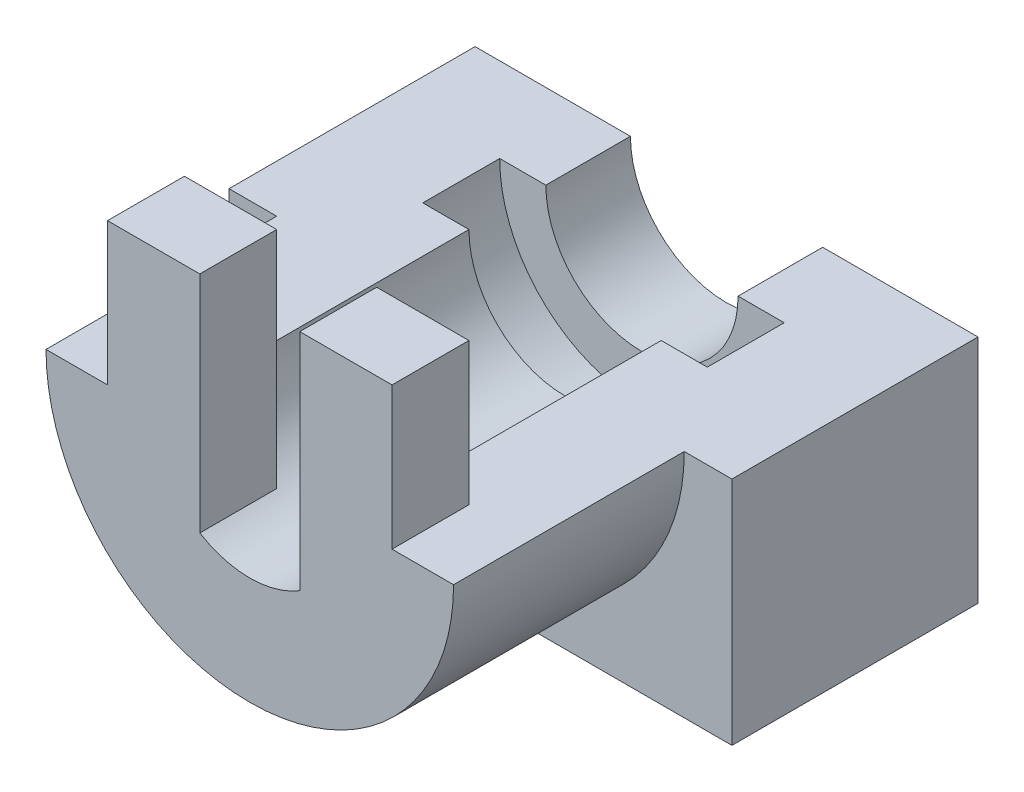
from build123d import *

# Parameters (mm, degrees)
EXTRUDE_1_DEPTH = 5
EXTRUDE_3_DEPTH = 10
EXTRUDE_4_DEPTH = 10.5
EXTRUDE_6_DEPTH = 15
EXTRUDE_7_DEPTH = 5.5
EXTRUDE_8_DEPTH = 5.5


with BuildPart() as part:
    # 草图1 → 凸台-拉伸1 (new body)
    with BuildSketch(Plane.XY):
        with BuildLine():
            Line((-3.25, 9.25), (-9.25, 9.25))
            Line((-9.25, 9.25), (-9.25, -1.7e-08))
            ThreePointArc((-9.25, -1.7e-08), (9e-09, -9.25), (9.25, 0))
            Line((9.25, 0), (9.25, 9.25))
            Line((9.25, 9.25), (3.25, 9.25))
            Line((3.25, 9.25), (3.25, -5.338539126))
            ThreePointArc((3.25, -5.338539126), (0, -6.25), (-3.25, -5.338539126))
            Line((-3.25, -5.338539126), (-3.25, 9.25))
        make_face()
    extrude(amount=EXTRUDE_1_DEPTH)

    # 草图1<4> → 凸台-拉伸3 (add)
    with BuildSketch(Plane.XY):
        with BuildLine():
            Line((-6.25, 0), (-9.25, 0))
            ThreePointArc((-9.25, -1.7e-08), (9e-09, -9.25), (9.25, 0))
            Line((9.25, 0), (6.25, 0))
            ThreePointArc((6.25, 0), (9e-09, -6.25), (-6.25, -1.8e-08))
        make_face()
    extrude(amount=-EXTRUDE_3_DEPTH)



with BuildPart() as body_2:
    # 草图2 → 凸台-拉伸4 (new body)
    with BuildSketch(Plane(origin=(0, 0, -10), x_dir=(-1, 0, 0), z_dir=(0, 0, -1))):
        with BuildLine():
            ThreePointArc((9.25, 0), (0, -9.25), (-9.25, 0))
            Line((-9.25, 0), (-16.35, 0))
            Line((-16.35, 0), (-16.35, -15))
            Line((-16.35, -15), (16.35, -15))
            Line((16.35, -15), (16.35, 0))
            Line((16.35, 0), (9.25, 0))
        make_face()
    extrude(amount=EXTRUDE_4_DEPTH)


with BuildPart() as part_1:
    add(part.part)

    add(body_2.part)  # 凸台-拉伸6 merges body 2
    # 草图5 → 凸台-拉伸6 (add)
    with BuildSketch(Plane.XY.offset(-10)):
        with BuildLine():
            ThreePointArc((9.25, 0), (0, -9.25), (-9.25, 0))
            Line((-9.25, 0), (-13.25, 0))
            ThreePointArc((-13.25, 0), (0, -13.25), (13.25, 0))
            Line((13.25, 0), (9.25, 0))
        make_face()
    extrude(amount=EXTRUDE_6_DEPTH)

    # 草图6 → 凸台-拉伸7 (add)
    with BuildSketch(Plane(origin=(0, 0, -10), x_dir=(-1, 0, 0), z_dir=(0, 0, -1))):
        with BuildLine():
            Line((9.25, 0), (6.25, 0))
            ThreePointArc((6.25, 0), (0, -6.25), (-6.25, 0))
            Line((-6.25, 0), (-9.25, 0))
            ThreePointArc((-9.25, 0), (0, -9.25), (9.25, 0))
        make_face()
    extrude(amount=EXTRUDE_7_DEPTH)

    # 草图7 → 凸台-拉伸8 (add)
    with BuildSketch(Plane(origin=(0, 0, -20.5), x_dir=(-1, 0, 0), z_dir=(0, 0, -1))):
        with BuildLine():
            Line((16.35, 0), (16.35, -15))
            Line((16.35, -15), (-16.35, -15))
            Line((-16.35, -15), (-16.35, 0))
            Line((-16.35, 0), (-6.25, 0))
            ThreePointArc((-6.25, 0), (0, -6.25), (6.25, 0))
            Line((6.25, 0), (16.35, 0))
        make_face()
    extrude(amount=EXTRUDE_8_DEPTH)


solid = part_1.part
